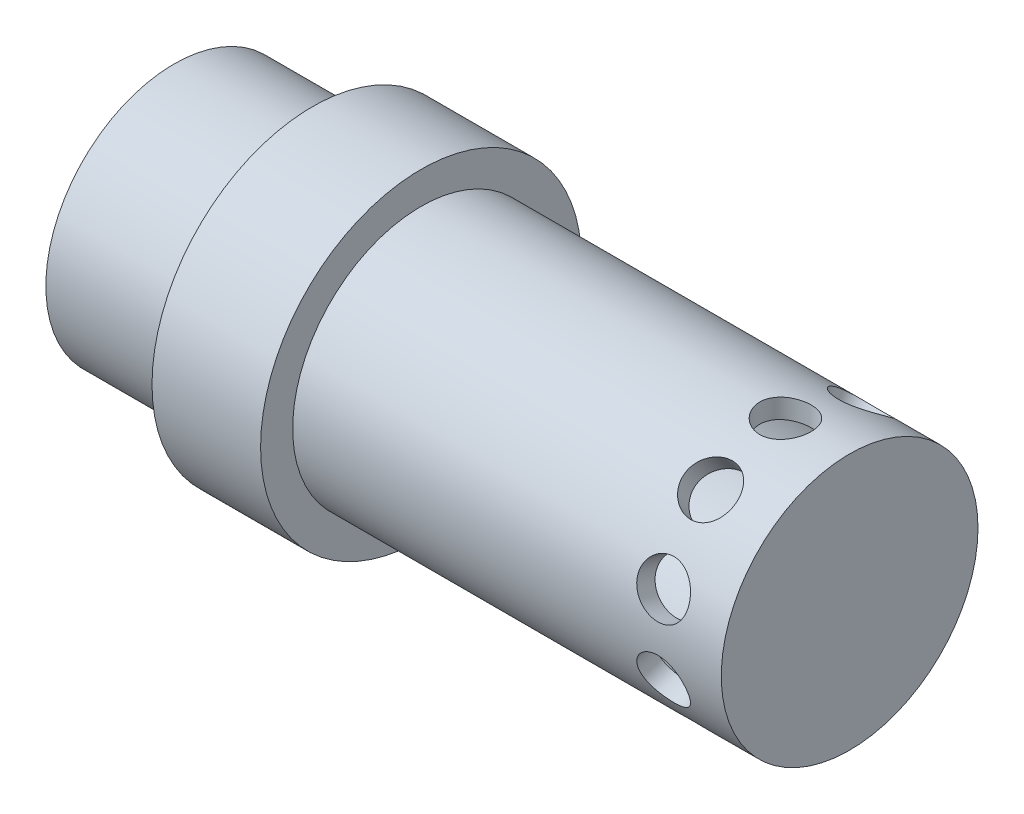
from build123d import *

# Parameters (mm, degrees)
CUT_EXTRUDE1_REACH      = 113.025
CUT_EXTRUDE1_END_RADIUS = 20
SKETCH2_R               = 4
CIRPATTERN1_COUNT       = 10


with BuildPart() as part:
    # Sketch1 → Revolve1 (revolve)
    with BuildSketch(Plane.XY, mode=Mode.PRIVATE) as revolve1_sk:
        Polygon((0, 0), (0, 20), (-66.784359743, 20), (-66.784359743, 25), (-83.702975636, 25), (-83.702975636, 20), (-105.24487755, 20), (-105.24487755, 17), (-3, 17), (-3, 0), align=None)
    revolve(revolve1_sk.sketch.rotate(Axis((27.57498519, 0, 0), (-1, 0, 0)), 90), axis=Axis((27.57498519, 0, 0), (-1, 0, 0)))

    # Cut-Extrude1: up to this cylinder (the profile starts inside it)
    cut_extrude1_end = Plane(origin=(-10, 0, 0), z_dir=(1, 0, 0)) * Cylinder(CUT_EXTRUDE1_END_RADIUS, 267.05, mode=Mode.PRIVATE)
    # Sketch2 → Cut-Extrude1 (cut, up to the surface)
    with BuildSketch(Plane(origin=(0, 0, 0), x_dir=(1, 0, 0), z_dir=(0, 1, 0)), mode=Mode.PRIVATE) as cut_extrude1_sk1:
        with Locations(Location((-10, 0, 0), (0, 0, 90))):
            Circle(SKETCH2_R)
    cut_extrude1_tool1 = extrude(cut_extrude1_sk1.sketch, amount=CUT_EXTRUDE1_REACH, mode=Mode.PRIVATE) & cut_extrude1_end
    cut_extrude1 = cut_extrude1_tool1.solids().sort_by_distance((-10, 0, 0))[0]
    add(cut_extrude1, mode=Mode.SUBTRACT)

    # CirPattern1: Cut-Extrude1 ×10 about axis
    cirpattern1_axis = Axis((27.57498519, 0, 0), (-1, 0, 0))
    for i in range(1, CIRPATTERN1_COUNT):
        add(cut_extrude1.rotate(cirpattern1_axis, i * 360 / CIRPATTERN1_COUNT), mode=Mode.SUBTRACT)


solid = part.part
